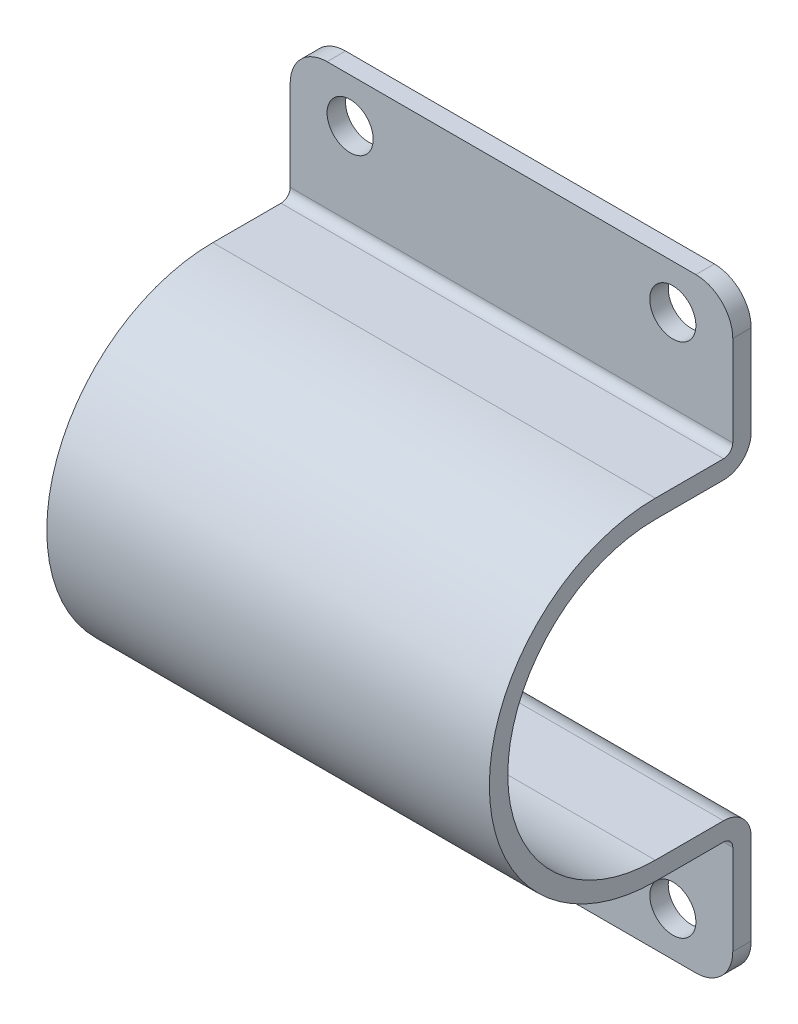
from build123d import *

# Parameters (mm, degrees)
BOSS_EXTRUDE1_DEPTH     = 240
SKETCH2_R               = 12.5
CUT_EXTRUDE1_DEPTH      = 133
CUT_EXTRUDE1_DEPTH_BACK = 11
FILLET1_R               = 20


with BuildPart() as part:
    # Sketch1 → Boss-Extrude1 (new body)
    with BuildSketch(Plane.YZ):
        with BuildLine():
            Line((164, 0), (95, 0))
            ThreePointArc((95, 0), (84.393398282, 4.393398282), (80, 15))
            Line((80, 15), (80, 52))
            ThreePointArc((80, 52), (0, 132), (-80, 52))
            Line((-80, 52), (-80, 15))
            ThreePointArc((-80, 15), (-84.393398282, 4.393398282), (-95, 0))
            Line((-95, 0), (-164, 0))
            Line((-164, 0), (-164, 10))
            Line((-164, 10), (-95, 10))
            ThreePointArc((-95, 10), (-91.464466094, 11.464466094), (-90, 15))
            Line((-90, 15), (-90, 52))
            ThreePointArc((-90, 52), (0, 142), (90, 52))
            Line((90, 52), (90, 15))
            ThreePointArc((90, 15), (91.464466094, 11.464466094), (95, 10))
            Line((95, 10), (164, 10))
            Line((164, 10), (164, 0))
        make_face()
    extrude(amount=BOSS_EXTRUDE1_DEPTH)

    # Sketch2 → Cut-Extrude1 (cut, two sides)
    with BuildSketch(Plane.XY.offset(10)) as cut_extrude1_sk:
        with Locations((32.5, 140)):
            Circle(SKETCH2_R)
        with Locations((207.5, 140)):
            Circle(SKETCH2_R)
        with Locations((207.5, -140)):
            Circle(SKETCH2_R)
        with Locations((32.5, -140)):
            Circle(SKETCH2_R)
    extrude(amount=CUT_EXTRUDE1_DEPTH, mode=Mode.SUBTRACT)
    extrude(cut_extrude1_sk.sketch, amount=-CUT_EXTRUDE1_DEPTH_BACK, mode=Mode.SUBTRACT)

    # Fillet1
    fillet1_edges = [part.edges().sort_by_distance(p)[0] for p in [
        (0, -164, 5),
        (0, 164, 5),
        (240, -164, 5),
        (240, 164, 5),
    ]]
    fillet(fillet1_edges, radius=FILLET1_R)


solid = part.part
